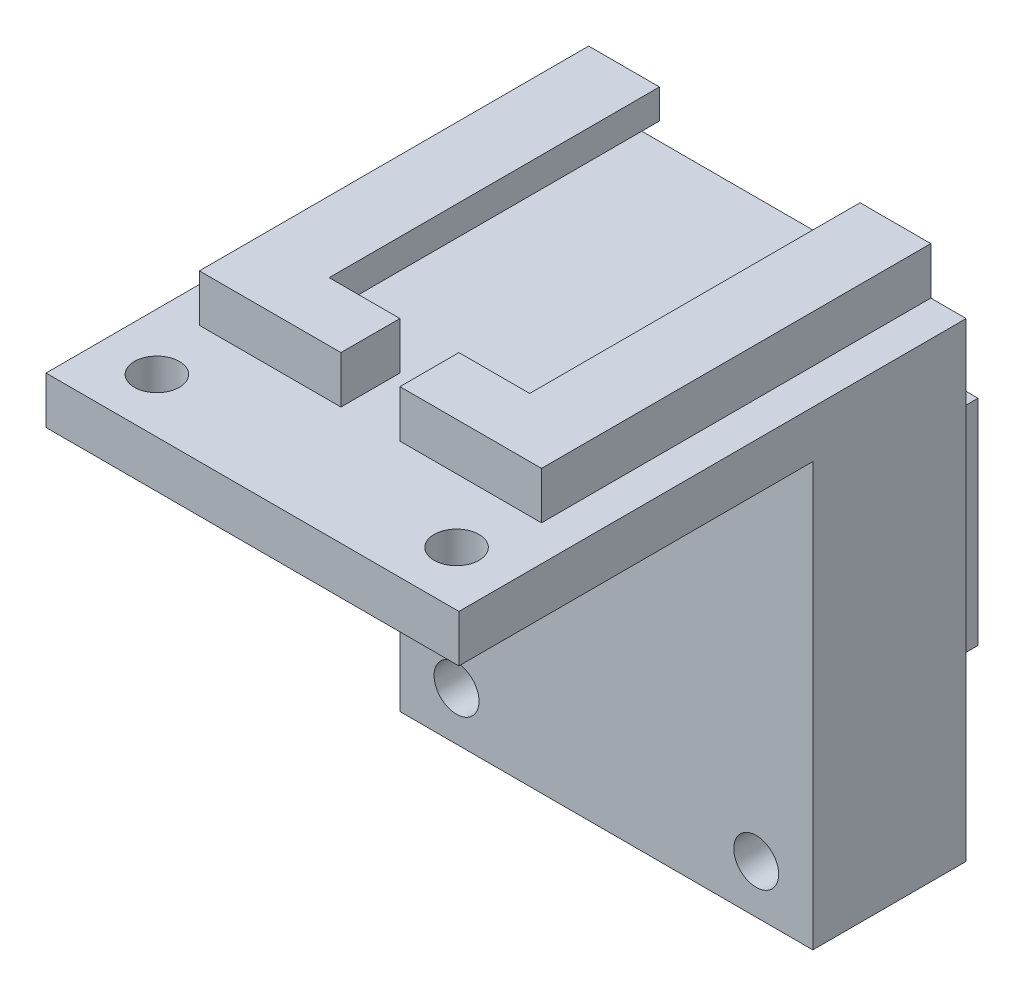
from build123d import *

# Parameters (mm, degrees)
SKETCH1_W               = 29
SKETCH1_H               = 15
BOSS_EXTRUDE1_DEPTH     = 8
SKETCH2_W               = 17
SKETCH2_H               = 2.5
SKETCH2_W_2             = 21
SKETCH2_H_2             = 2
CUT_EXTRUDE1_DEPTH      = 1
CUT_EXTRUDE1_DEPTH_BACK = 16
SKETCH4_W               = 5
SKETCH4_H               = 3.5
BOSS_EXTRUDE2_DEPTH     = 5
SKETCH5_W               = 35
SKETCH5_H               = 30
BOSS_EXTRUDE3_DEPTH     = 4
SKETCH6_R               = 1.905
CUT_EXTRUDE2_DEPTH      = 1
CUT_EXTRUDE2_DEPTH_BACK = 9
SKETCH9_W               = 35
SKETCH9_H               = 39.85
BOSS_EXTRUDE4_DEPTH     = 13
SKETCH10_R              = 1.905
CUT_EXTRUDE4_DEPTH      = 13
SKETCH11_W              = 29
SKETCH11_H              = 13.15
BOSS_EXTRUDE5_DEPTH     = 4
SKETCH12_W              = 17
SKETCH12_H              = 2.5
CUT_EXTRUDE5_DEPTH      = 31.5
SKETCH13_W              = 12
SKETCH13_H              = 4
BOSS_EXTRUDE6_DEPTH     = 5
BOSS_EXTRUDE7_DEPTH     = 13


with BuildPart() as part:
    # Sketch1 → Boss-Extrude1 (new body)
    with BuildSketch(Plane(origin=(0, 0, 0), x_dir=(1, 0, 0), z_dir=(0, 1, 0))):
        with Locations((14.5, 7.5)):
            Rectangle(SKETCH1_W, SKETCH1_H)
    extrude(amount=BOSS_EXTRUDE1_DEPTH)

    # Sketch2 → Cut-Extrude1 (cut, two sides)
    with BuildSketch(Plane.XY) as cut_extrude1_sk:
        with Locations((14.5, 6.75)):
            Rectangle(SKETCH2_W, SKETCH2_H)
        with Locations((14.5, 4.5)):
            Rectangle(SKETCH2_W_2, SKETCH2_H_2)
    extrude(amount=CUT_EXTRUDE1_DEPTH, mode=Mode.SUBTRACT)
    extrude(cut_extrude1_sk.sketch, amount=-CUT_EXTRUDE1_DEPTH_BACK, mode=Mode.SUBTRACT)

    # Sketch4 → Boss-Extrude2 (add)
    with BuildSketch(Plane.XY):
        with Locations((14.5, 1.75)):
            Rectangle(SKETCH4_W, SKETCH4_H)
        Polygon((17, 3.5), (17, 0), (29, 0), (29, 8), (23, 8), (23, 5.5), (25, 5.5), (25, 3.5), align=None)
        Polygon((6, 8), (0, 8), (0, 0), (12, 0), (12, 3.5), (4, 3.5), (4, 5.5), (6, 5.5), align=None)
        Polygon((12, 8), (6, 8), (6, 5.5), (4, 5.5), (4, 3.5), (12, 3.5), align=None)
        Polygon((23, 8), (17, 8), (17, 3.5), (25, 3.5), (25, 5.5), (23, 5.5), align=None)
    extrude(amount=BOSS_EXTRUDE2_DEPTH)

    # Sketch5 → Boss-Extrude3 (add)
    with BuildSketch(Plane(origin=(0, 0, 0), x_dir=(-1, 0, 0), z_dir=(0, -1, 0))):
        with Locations((-14.5, 0)):
            Rectangle(SKETCH5_W, SKETCH5_H)
    extrude(amount=-BOSS_EXTRUDE3_DEPTH)

    # Sketch6 → Cut-Extrude2 (cut, two sides)
    with BuildSketch(Plane(origin=(0, 0, 0), x_dir=(-1, 0, 0), z_dir=(0, -1, 0))) as cut_extrude2_sk:
        with Locations((-27.2, -10.4)):
            Circle(SKETCH6_R)
        with Locations((-1.8, -10.4)):
            Circle(SKETCH6_R)
    extrude(amount=CUT_EXTRUDE2_DEPTH, mode=Mode.SUBTRACT)
    extrude(cut_extrude2_sk.sketch, amount=-CUT_EXTRUDE2_DEPTH_BACK, mode=Mode.SUBTRACT)

    # Sketch9 → Boss-Extrude4 (add)
    with BuildSketch(Plane(origin=(0, 0, -15), x_dir=(-1, 0, 0), z_dir=(0, 0, -1))):
        with Locations((-14.5, -15.925)):
            Rectangle(SKETCH9_W, SKETCH9_H)
    extrude(amount=BOSS_EXTRUDE4_DEPTH)

    # Sketch10 → Cut-Extrude4 (cut)
    with BuildSketch(Plane.XY.offset(-15)):
        with Locations((1.8, -31.75)):
            Circle(SKETCH10_R)
        with Locations((27.2, -31.75)):
            Circle(SKETCH10_R)
    extrude(amount=-CUT_EXTRUDE4_DEPTH, mode=Mode.SUBTRACT)

    # Sketch11 → Boss-Extrude5 (add)
    with BuildSketch(Plane(origin=(0, 0, -28), x_dir=(-1, 0, 0), z_dir=(0, 0, -1))):
        with Locations((-14.5, -11.925)):
            Rectangle(SKETCH11_W, SKETCH11_H)
    extrude(amount=BOSS_EXTRUDE5_DEPTH)

    # Sketch12 → Cut-Extrude5 (cut, through all)
    with BuildSketch(Plane(origin=(0, -5.35, 0), x_dir=(1, 0, 0), z_dir=(0, 1, 0))):
        Polygon((4, 29.5), (4, 28), (25, 28), (25, 29.5), (23, 29.5), (6, 29.5), align=None)
        with Locations((14.5, 30.75)):
            Rectangle(SKETCH12_W, SKETCH12_H)
    extrude(amount=-CUT_EXTRUDE5_DEPTH, mode=Mode.SUBTRACT)

    # Sketch13 → Boss-Extrude6 (add)
    with BuildSketch(Plane(origin=(0, -18.5, 0), x_dir=(-1, 0, 0), z_dir=(0, -1, 0))):
        with Locations((-6, 30)):
            Rectangle(SKETCH13_W, SKETCH13_H)
        with Locations((-23, 30)):
            Rectangle(SKETCH13_W, SKETCH13_H)
    extrude(amount=BOSS_EXTRUDE6_DEPTH)

    # Sketch14 → Boss-Extrude7 (add)
    with BuildSketch(Plane(origin=(0, 0, -15), x_dir=(-1, 0, 0), z_dir=(0, 0, -1))):
        Polygon((0, 4), (0, 8), (-6, 8), (-6, 5.5), (-4, 5.5), (-4, 4), align=None)
        Polygon((-23, 5.5), (-23, 8), (-29, 8), (-29, 4), (-25, 4), (-25, 5.5), align=None)
    extrude(amount=BOSS_EXTRUDE7_DEPTH)


solid = part.part
